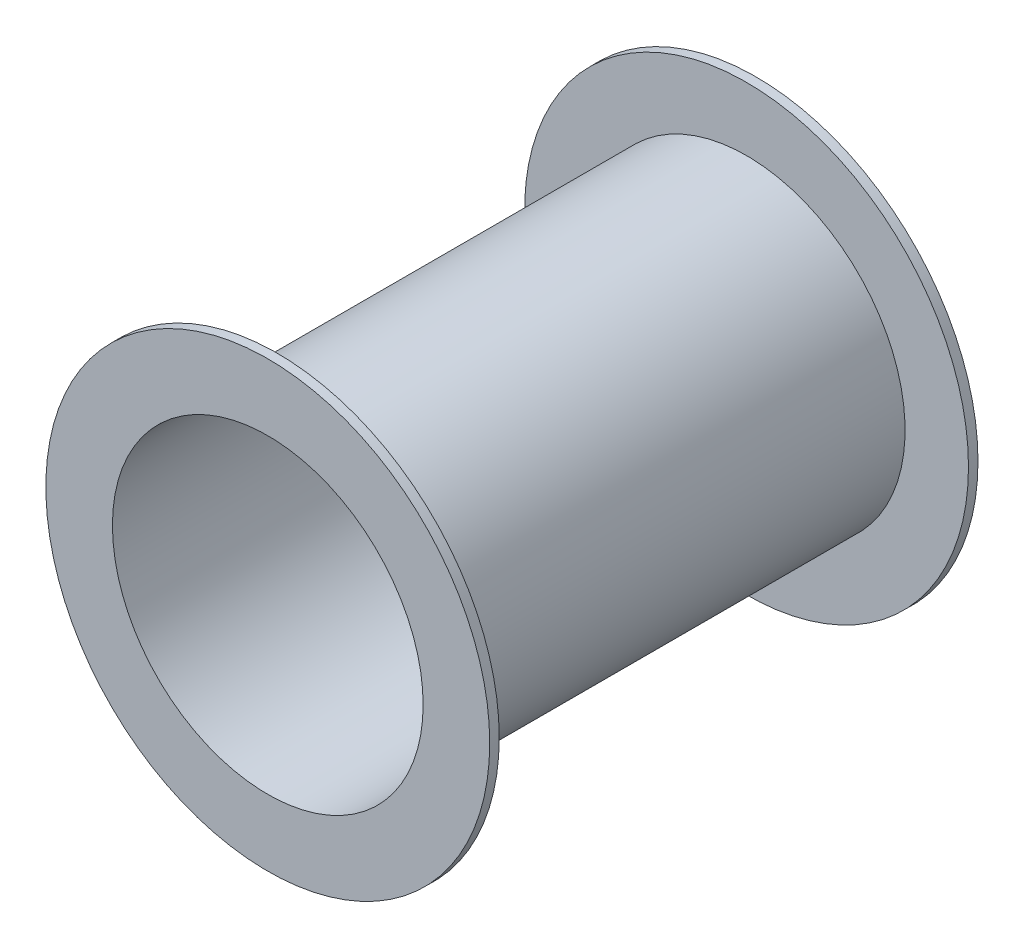
from build123d import *

# Parameters (mm, degrees)
SKETCH1_R           = 100
SKETCH1_R_2         = 98
EXTRUDE_THIN1_DEPTH = 308
SKETCH2_R           = 140
SKETCH2_R_2         = 100
BOSS_EXTRUDE1_DEPTH = 6


with BuildPart() as part:
    # Sketch1 → Extrude-Thin1 (new body)
    with BuildSketch(Plane.XY):
        Circle(SKETCH1_R)
        Circle(SKETCH1_R_2, mode=Mode.SUBTRACT)
    extrude_thin1 = extrude(amount=EXTRUDE_THIN1_DEPTH)

    # Sketch2 → Boss-Extrude1 (add)
    with BuildSketch(Plane.XY.offset(308)):
        Circle(SKETCH2_R)
        Circle(SKETCH2_R_2, mode=Mode.SUBTRACT)
    boss_extrude1 = extrude(amount=-BOSS_EXTRUDE1_DEPTH)

    # Mirror1: Extrude-Thin1, Boss-Extrude1 across plane
    add(extrude_thin1.mirror(Plane(origin=(0, 0, 154), x_dir=(1, 0, 0), z_dir=(0, 0, -1))))
    add(boss_extrude1.mirror(Plane(origin=(0, 0, 154), x_dir=(1, 0, 0), z_dir=(0, 0, -1))))


solid = part.part
